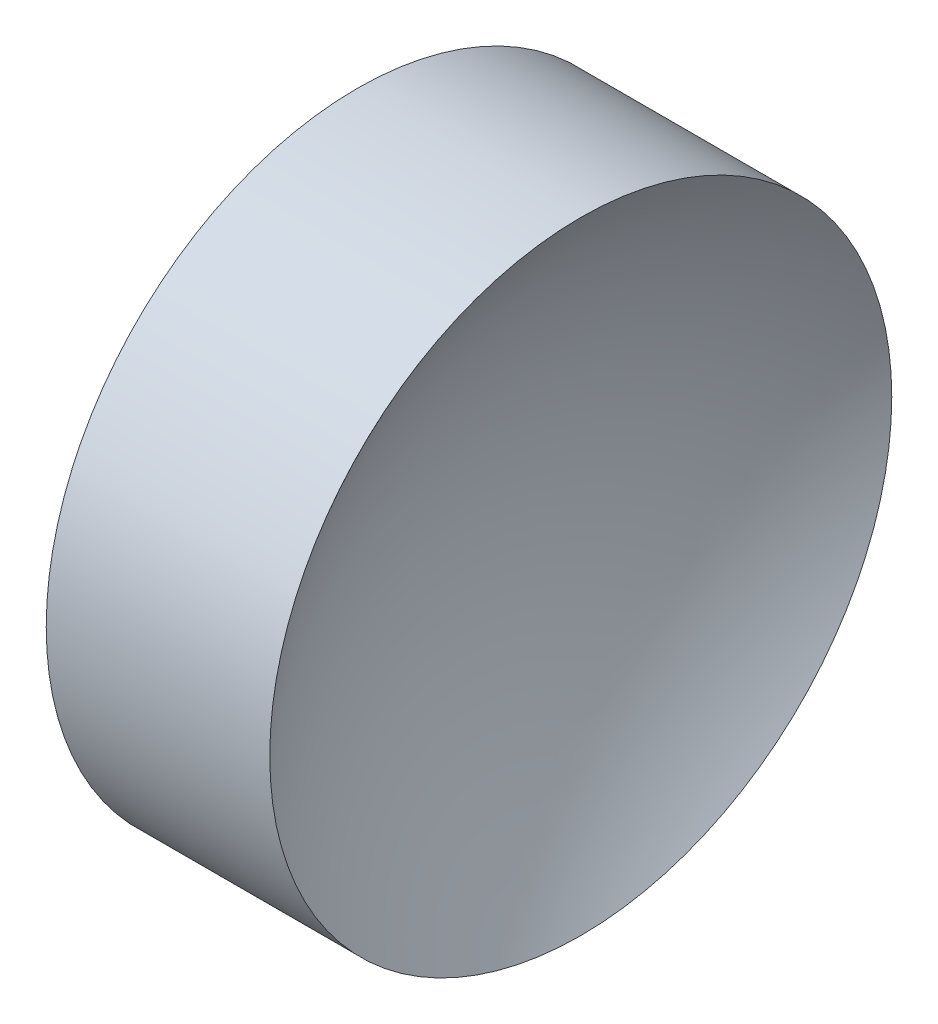
from build123d import *


with BuildPart() as part:
    # 草图1 → 旋转1 (revolve)
    with BuildSketch(Plane.XY, mode=Mode.PRIVATE) as revolve_1_sk:
        with BuildLine():
            Line((47.744711016, 28.477595635), (47.744711016, 34.827595635))
            Line((47.744711016, 34.827595635), (52.308722234, 34.827595635))
            ThreePointArc((52.308722234, 34.827595635), (50.77366728, 31.816107365), (50.244711016, 28.477595635))
            Line((50.244711016, 28.477595635), (47.744711016, 28.477595635))
        make_face()
    revolve(revolve_1_sk.sketch.rotate(Axis((44.782091903, 28.477595635, 0), (1, 0, 0)), 180), axis=Axis((44.782091903, 28.477595635, 0), (1, 0, 0)))  # turned: the seam where the file's is


solid = part.part
